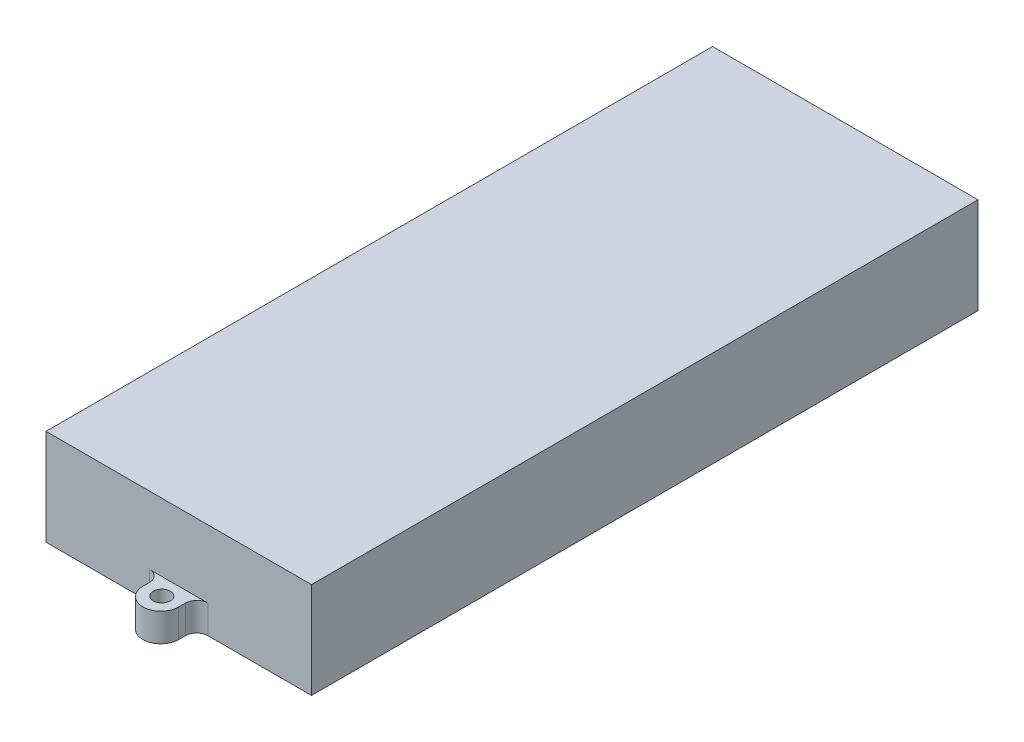
from build123d import *

# Parameters (mm, degrees)
SKETCH1_W           = 47
SKETCH1_H           = 118
BOSS_EXTRUDE1_DEPTH = 17
BOSS_EXTRUDE2_DEPTH = 5
SKETCH3_R           = 1.5
CUT_EXTRUDE1_DEPTH  = 6
FILLET2_R           = 2


with BuildPart() as part:
    # Sketch1 → Boss-Extrude1 (new body)
    with BuildSketch(Plane(origin=(0, 0, 0), x_dir=(1, 0, 0), z_dir=(0, 1, 0))):
        Rectangle(SKETCH1_W, SKETCH1_H)
    extrude(amount=BOSS_EXTRUDE1_DEPTH)

    # Sketch2 → Boss-Extrude2 (add)
    with BuildSketch(Plane(origin=(0, 0, 0), x_dir=(1, 0, 0), z_dir=(0, 1, 0))):
        with BuildLine():
            Line((-3.175, 62.175), (-3.175, 59))
            Line((-3.175, 59), (3.175, 59))
            Line((3.175, 59), (3.175, 62.175))
            ThreePointArc((3.175, 62.175), (0, 65.35), (-3.175, 62.175))
        make_face()
        with BuildLine():
            Line((3.175, -62.175), (3.175, -59))
            Line((3.175, -59), (-3.175, -59))
            Line((-3.175, -59), (-3.175, -62.175))
            ThreePointArc((-3.175, -62.175), (0, -65.35), (3.175, -62.175))
        make_face()
    extrude(amount=BOSS_EXTRUDE2_DEPTH)

    # Sketch3 → Cut-Extrude1 (cut, through all)
    with BuildSketch(Plane(origin=(0, 5, 0), x_dir=(1, 0, 0), z_dir=(0, 1, 0))):
        with Locations((0, -62)):
            Circle(SKETCH3_R)
        with Locations((0, 62)):
            Circle(SKETCH3_R)
    extrude(amount=-CUT_EXTRUDE1_DEPTH, mode=Mode.SUBTRACT)

    # Fillet2
    fillet2_edges = [part.edges().sort_by_distance(p)[0] for p in [
        (-3.175, 2.5, -59),
        (3.175, 2.5, -59),
        (3.175, 2.5, 59),
        (-3.175, 2.5, 59),
    ]]
    fillet(fillet2_edges, radius=FILLET2_R)


solid = part.part
